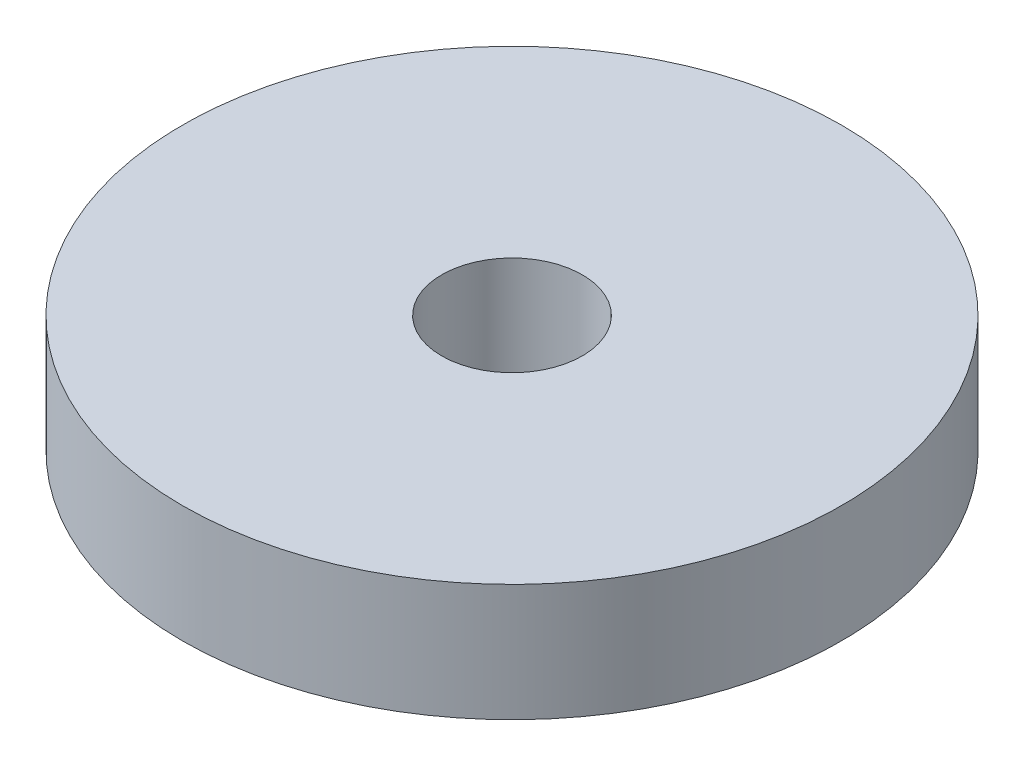
from build123d import *

# Parameters (mm, degrees)
SKETCH1_R           = 8.92937
BOSS_EXTRUDE1_DEPTH = 3.175
SKETCH2_R           = 1.905
CUT_EXTRUDE1_DEPTH  = 3.175


with BuildPart() as part:
    # Sketch1 → Boss-Extrude1 (new body)
    with BuildSketch(Plane(origin=(0, 0, 0), x_dir=(1, 0, 0), z_dir=(0, 1, 0))):
        Circle(SKETCH1_R)
    extrude(amount=BOSS_EXTRUDE1_DEPTH)

    # Sketch2 → Cut-Extrude1 (cut)
    with BuildSketch(Plane(origin=(0, 3.175, 0), x_dir=(1, 0, 0), z_dir=(0, 1, 0))):
        Circle(SKETCH2_R)
    extrude(amount=-CUT_EXTRUDE1_DEPTH, mode=Mode.SUBTRACT)


solid = part.part
